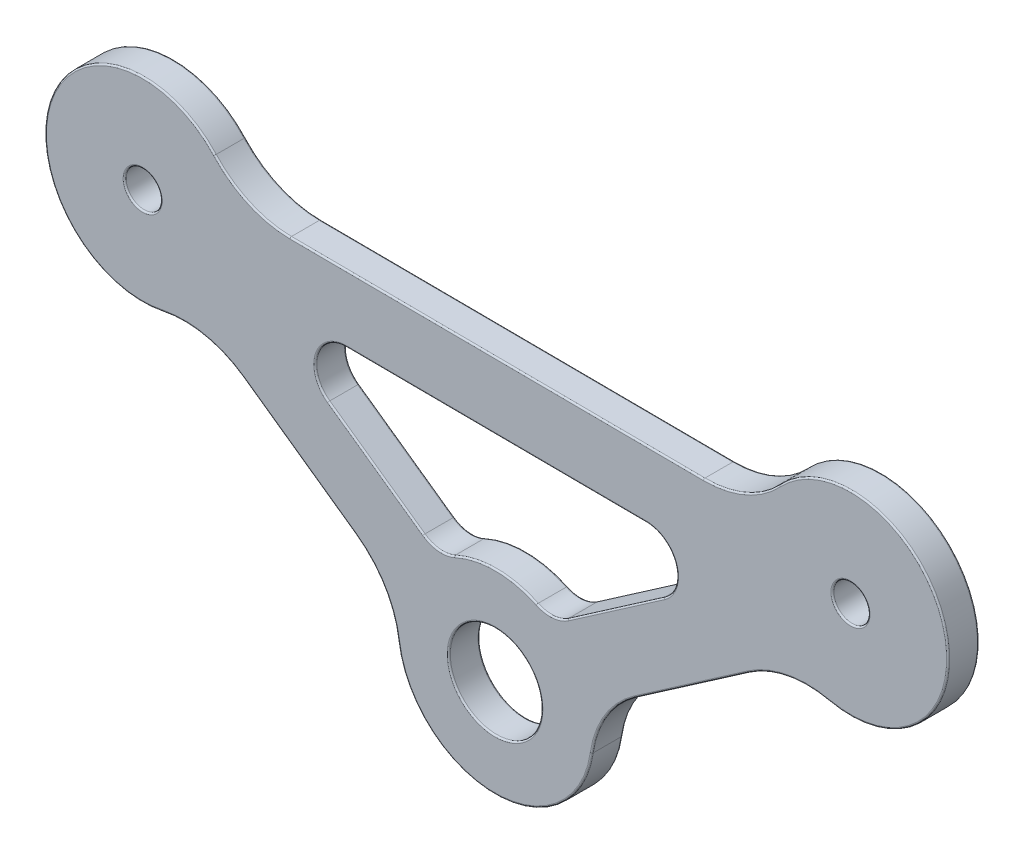
from build123d import *

# Parameters (mm, degrees)
SZKIC2_R                          = 9.5
SZKIC2_R_2                        = 1.75
DODANIE_WYCI_GNI_CIE1_DEPTH       = 3
SZKIC2_R_3                        = 4.5
DODANIE_WYCI_GNI_CIE1_2_DEPTH     = 3
DODANIE_WYCI_GNI_CIE1_3_DEPTH     = 3
WYCI_GNI_CIE_CIENKA_CIANKA1_DEPTH = 3
ZAOKR_GLENIE1_R                   = 3
ZAOKR_GLENIE2_R                   = 3
ZAOKR_GLENIE3_R                   = 3
ZAOKR_GLENIE6_R                   = 10
ZAOKR_GLENIE7_R                   = 0.15


with BuildPart() as part:
    # Szkic2 → Dodanie-wyciągnięcie1 (new body)
    with BuildSketch(Plane.XY):
        with Locations((-86.925055092, 226.277353864)):
            Circle(SZKIC2_R)
        with Locations((-86.925055092, 226.277353864)):
            Circle(SZKIC2_R_2, mode=Mode.SUBTRACT)
    extrude(amount=-DODANIE_WYCI_GNI_CIE1_DEPTH)



with BuildPart() as body_2:
    # Szkic2 → Dodanie-wyci_gni_cie1 2 (new body)
    with BuildSketch(Plane.XY):
        with Locations((-52.667069104, 201.979403415)):
            Circle(SZKIC2_R)
        with Locations((-52.667069104, 201.979403415)):
            Circle(SZKIC2_R_3, mode=Mode.SUBTRACT)
    extrude(amount=-DODANIE_WYCI_GNI_CIE1_2_DEPTH)


with BuildPart() as body_3:
    # Szkic2 → Dodanie-wyci_gni_cie1 3 (new body)
    with BuildSketch(Plane.XY):
        with Locations((-18.117543089, 225.860991555)):
            Circle(SZKIC2_R)
        with Locations((-18.117543089, 225.860991555)):
            Circle(SZKIC2_R_2, mode=Mode.SUBTRACT)
    extrude(amount=-DODANIE_WYCI_GNI_CIE1_3_DEPTH)


with BuildPart() as part_1:
    add(part.part)

    add(body_2.part)  # Wyciągnięcie-cienka ścianka1 merges body 2

    add(body_3.part)  # Wyciągnięcie-cienka ścianka1 merges body 3
    # Szkic3 → Wyciągnięcie-cienka ścianka1 (add)
    with BuildSketch(Plane.XY):
        Polygon((-45.883442496, 202.717583636), (-21.205209628, 219.775860879), (-24.901169697, 225.122811334), (-49.579402565, 208.064534091), align=None)
        Polygon((-25.00163332, 229.152707492), (-80.00163332, 229.485518929), (-80.040964861, 222.985637928), (-25.040964861, 222.65282649), align=None)
        Polygon((-83.91125564, 220.155302503), (-59.441265649, 202.799623611), (-55.680868556, 208.101454776), (-80.150858547, 225.457133668), align=None)
    extrude(amount=-WYCI_GNI_CIE_CIENKA_CIANKA1_DEPTH)

    # Zaokrąglenie1
    zaokr_glenie1_edges = [part_1.edges().sort_by_distance(p)[0] for p in [
        (-47.171806065, 209.728731394, -1.5),
        (-58.068148981, 209.794666441, -1.5),
    ]]
    fillet(zaokr_glenie1_edges, radius=ZAOKR_GLENIE1_R)

    # Zaokrąglenie2
    zaokr_glenie2_edges = [part_1.edges().sort_by_distance(p)[0] for p in [
        (-28.444703259, 222.67342291, -1.5),
    ]]
    fillet(zaokr_glenie2_edges, radius=ZAOKR_GLENIE2_R)

    # Zaokrąglenie3
    zaokr_glenie3_edges = [part_1.edges().sort_by_distance(p)[0] for p in [
        (-76.637226463, 222.965041509, -1.5),
    ]]
    fillet(zaokr_glenie3_edges, radius=ZAOKR_GLENIE3_R)

    # Zaokrąglenie6
    zaokr_glenie6_edges = [part_1.edges().sort_by_distance(p)[0] for p in [
        (-77.978767213, 229.47327833, -1.5),
        (-27.024499427, 229.164948091, -1.5),
        (-23.612806128, 218.111663576, -1.5),
        (-43.475845996, 204.381780939, -1.5),
        (-61.828546075, 204.492835276, -1.5),
        (-81.523975215, 218.462090839, -1.5),
    ]]
    fillet(zaokr_glenie6_edges, radius=ZAOKR_GLENIE6_R)

    # Zaokrąglenie7
    zaokr_glenie7_edges = [part_1.edges().sort_by_distance(p)[0] for p in [
        (-40.940848832, 214.035741403, -3),
        (-40.940848832, 214.035741403, 0),
        (-52.609584545, 211.479229493, -3),
        (-52.609584545, 211.479229493, 0),
        (-47.072508119, 210.285966007, 0),
        (-47.072508119, 210.285966007, -3),
        (-58.160696119, 210.353061931, 0),
        (-58.160696119, 210.353061931, -3),
        (-52.540964861, 222.819232209, -3),
        (-52.540964861, 222.819232209, 0),
        (-35.110909303, 220.615839894, -3),
        (-35.110909303, 220.615839894, 0),
        (-64.24652739, 214.176766792, 0),
        (-64.24652739, 214.176766792, -3),
        (-69.99640902, 220.826936136, 0),
        (-69.99640902, 220.826936136, -3),
        (-52.50163332, 229.31911321, -3),
        (-52.50163332, 229.31911321, 0),
        (-95.967914312, 229.188830659, 0),
        (-95.967914312, 229.188830659, -3),
        (-9.040111988, 228.662820353, -3),
        (-9.040111988, 228.662820353, 0),
        (-33.544326062, 211.246722258, -3),
        (-33.544326062, 211.246722258, 0),
        (-52.724553664, 192.479577336, -3),
        (-52.724553664, 192.479577336, 0),
        (-71.676260645, 211.477463057, 0),
        (-71.676260645, 211.477463057, -3),
        (-76.596817735, 230.301178851, 0),
        (-76.596817735, 230.301178851, -3),
        (-28.396328627, 230.00951205, 0),
        (-28.396328627, 230.00951205, -3),
        (-24.269968637, 216.640833515, 0),
        (-24.269968637, 216.640833515, -3),
        (-41.867687317, 204.47680355, 0),
        (-41.867687317, 204.47680355, -3),
        (-63.435437046, 204.607312528, 0),
        (-63.435437046, 204.607312528, -3),
        (-80.884660507, 216.983415642, -3),
        (-80.884660507, 216.983415642, 0),
        (-19.867543089, 225.860991555, -3),
        (-19.867543089, 225.860991555, 0),
        (-88.675055092, 226.277353864, -3),
        (-88.675055092, 226.277353864, 0),
        (-57.167069104, 201.979403415, -3),
        (-57.167069104, 201.979403415, 0),
    ]]
    fillet(zaokr_glenie7_edges, radius=ZAOKR_GLENIE7_R)


solid = part_1.part
